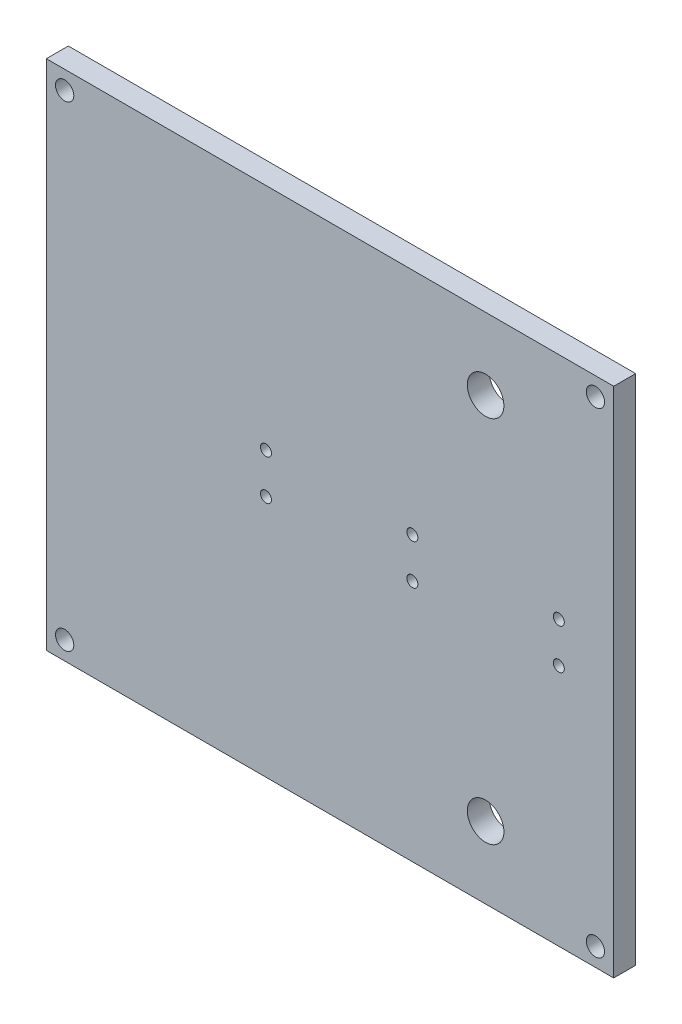
from build123d import *

# Parameters (mm, degrees)
ESQUISSE1_W             = 155
ESQUISSE1_H             = 140
ESQUISSE1_R             = 5
ESQUISSE1_R_2           = 2.5
BOSS_EXTRU_1_DEPTH      = 6
ESQUISSE6_R             = 1.5
ENL_V_MAT_EXTRU_1_DEPTH = 6


with BuildPart() as part:
    # Esquisse1 → Boss.-Extru.1 (new body)
    with BuildSketch(Plane.XY):
        with Locations((0, 5.5)):
            Rectangle(ESQUISSE1_W, ESQUISSE1_H)
        with Locations((42.5, -44.9)):
            Circle(ESQUISSE1_R, mode=Mode.SUBTRACT)
        with Locations((42.5, 55.875)):
            Circle(ESQUISSE1_R, mode=Mode.SUBTRACT)
        with Locations((-72.5, -59.5)):
            Circle(ESQUISSE1_R_2, mode=Mode.SUBTRACT)
        with Locations((-72.5, 70.5)):
            Circle(ESQUISSE1_R_2, mode=Mode.SUBTRACT)
        with Locations((72.5, -59.5)):
            Circle(ESQUISSE1_R_2, mode=Mode.SUBTRACT)
        with Locations((72.5, 70.5)):
            Circle(ESQUISSE1_R_2, mode=Mode.SUBTRACT)
    extrude(amount=BOSS_EXTRU_1_DEPTH)

    # Esquisse6 → Enlèv. mat.-Extru.1 (cut)
    with BuildSketch(Plane.XY.offset(6)):
        with Locations((-17.5, 12.875)):
            Circle(ESQUISSE6_R)
        with Locations((22.5, 12.875)):
            Circle(ESQUISSE6_R)
        with Locations((62.5, 12.875)):
            Circle(ESQUISSE6_R)
        with Locations((62.5, 1.875)):
            Circle(ESQUISSE6_R)
        with Locations((22.5, 1.875)):
            Circle(ESQUISSE6_R)
        with Locations((-17.5, 1.875)):
            Circle(ESQUISSE6_R)
    extrude(amount=-ENL_V_MAT_EXTRU_1_DEPTH, mode=Mode.SUBTRACT)


solid = part.part
